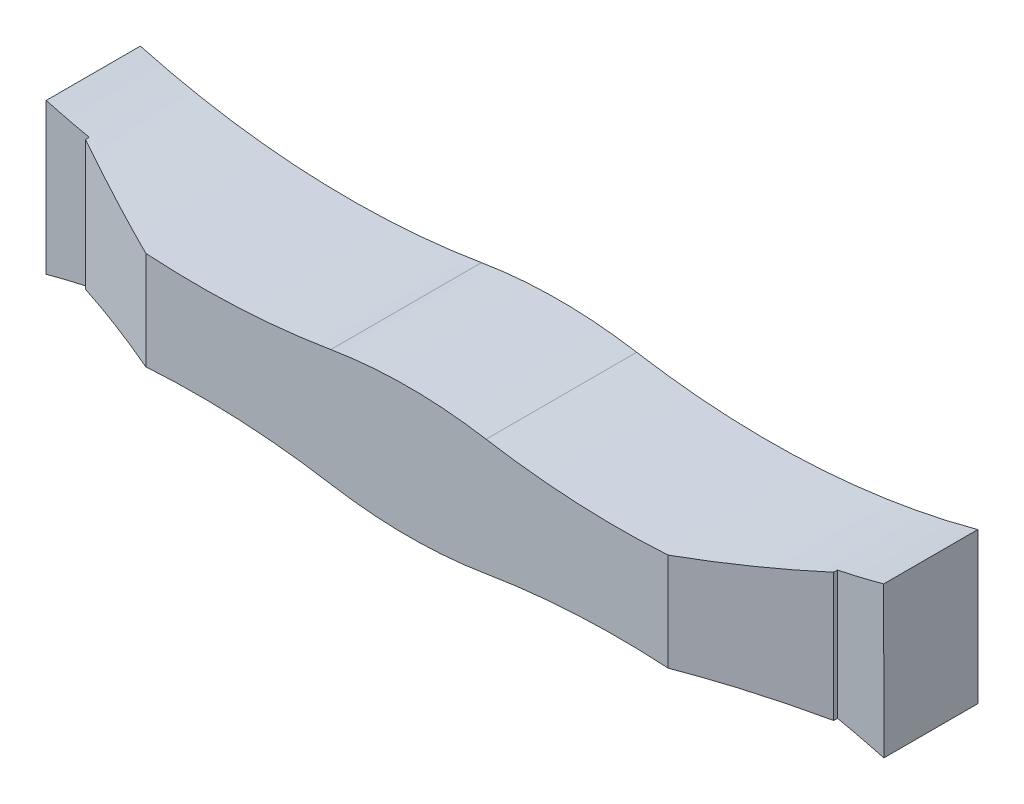
from build123d import *

# Parameters (mm, degrees)
BOSS_EXTRUDE1_DEPTH = 2
BOSS_EXTRUDE2_DEPTH = 3.2
CUT_EXTRUDE1_DEPTH  = 4.200000092
FILLET1_R           = 10


with BuildPart() as part:
    # Sketch3 → Boss-Extrude1 (new body)
    with BuildSketch(Plane.XY.offset(13)):
        Polygon((-3.57e-07, 1.6), (8.295592088, 1.6), (8.93017926, 1.6), (8.934835346, -1.6), (8.268122338, -1.6), (-8.285812718, -1.6), (-8.869806966, -1.6), (-8.865150879, 1.6), (-8.277696583, 1.6), align=None)
    extrude(amount=-BOSS_EXTRUDE1_DEPTH)

    # Sketch4 → Boss-Extrude2 (add)
    with BuildSketch(Plane.XZ.offset(1.6)):
        Polygon((-7.949410938, 13.000000268), (7.949410938, 13.000000268), (7.949410938, 13.080862351), (5.549410824, 14.200000092), (-5.549410824, 14.200000092), (-7.949410938, 13.080862351), align=None)
    extrude(amount=-BOSS_EXTRUDE2_DEPTH)

    # Sketch5 → Cut-Extrude1 (cut, through all)
    with BuildSketch(Plane(origin=(0, 0, 11), x_dir=(-1, 0, 0), z_dir=(0, 0, -1))):
        with BuildLine():
            ThreePointArc((-0.03251419, -1.6), (-4.481346725, -1.006559792), (-8.93017926, -1.6))
            Line((-8.93017926, -1.6), (-0.03251419, -1.6))
        make_face()
        with BuildLine():
            ThreePointArc((8.865150879, -1.6), (4.416318345, -1.006559792), (-0.03251419, -1.6))
            Line((-0.03251419, -1.6), (8.865150879, -1.6))
        make_face()
        with BuildLine():
            Line((8.865150879, 1.6), (-0.03251419, 1.6))
            ThreePointArc((-0.03251419, 1.6), (4.416318345, 1.006559792), (8.865150879, 1.6))
        make_face()
        with BuildLine():
            Line((-0.03251419, 1.6), (-8.93017926, 1.6))
            ThreePointArc((-8.93017926, 1.6), (-4.481346725, 1.006559792), (-0.03251419, 1.6))
        make_face()
    extrude(amount=-CUT_EXTRUDE1_DEPTH, mode=Mode.SUBTRACT)

    # Fillet1
    fillet1_edges = [part.edges().sort_by_distance(p)[0] for p in [
        (0.03251419, -1.6, 12.600000046),
        (0.03251419, 1.6, 12.600000046),
    ]]
    fillet(fillet1_edges, radius=FILLET1_R)


solid = part.part
